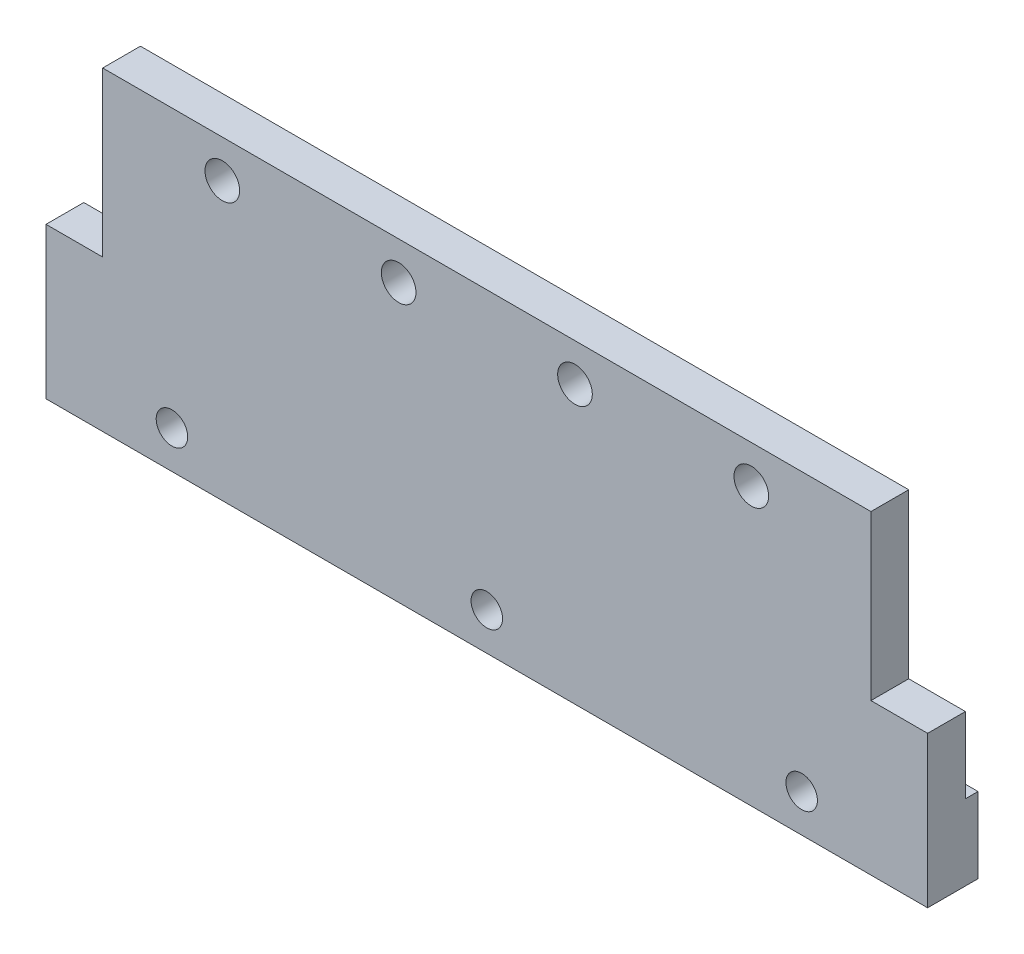
from build123d import *

# Parameters (mm, degrees)
SKETCH_1_W          = 140
SKETCH_1_H          = 50
EXTRUDE_1_DEPTH     = 6
SKETCH_6_R          = 2.75
CUT_EXTRUDE_4_DEPTH = 7
SKETCH_5_W          = 140
SKETCH_5_H          = 12
EXTRUDE_3_DEPTH     = 2
M6X1_01_AT_2_COUNT  = 2
M6X1_01_AT_2_PITCH  = 50
M6X1_01_AT_3_COUNT  = 2
M6X1_01_AT_3_PITCH  = 50
SKETCH_4_W          = 9
SKETCH_4_H          = 26
CUT_EXTRUDE_2_DEPTH = 9


with BuildPart() as part:
    # Эскиз1 → Вытянуть1 (new body)
    with BuildSketch(Plane.XY):
        Rectangle(SKETCH_1_W, SKETCH_1_H)
    extrude(amount=EXTRUDE_1_DEPTH)

    # Эскиз6 → Вытянуть4 (cut, through all)
    with BuildSketch(Plane(origin=(0, 0, 0), x_dir=(-1, 0, 0), z_dir=(0, 0, -1))):
        with Locations((42, 19)):
            Circle(SKETCH_6_R)
        with Locations((14, 19)):
            Circle(SKETCH_6_R)
        with Locations((-14, 19)):
            Circle(SKETCH_6_R)
        with Locations((-42, 19)):
            Circle(SKETCH_6_R)
    extrude(amount=-CUT_EXTRUDE_4_DEPTH, mode=Mode.SUBTRACT)

    # Эскиз5 → Вытянуть3 (add)
    with BuildSketch(Plane(origin=(0, 0, 0), x_dir=(-1, 0, 0), z_dir=(0, 0, -1))):
        with Locations((0, -19)):
            Rectangle(SKETCH_5_W, SKETCH_5_H)
    extrude(amount=EXTRUDE_3_DEPTH)

    # Эскиз2 → Отверстие обработанное метчиком M6x1.01 (revolve, cut)
    with BuildSketch(Plane(origin=(0, -19, 6), x_dir=(0, -1, 0), z_dir=(1, 0, 0))):
        Polygon((0, 0), (0, 8.000025), (3.25, 8.000025), (2.5, 7.250025), (2.5, 0), align=None)
    m6x1_01 = revolve(axis=Axis((0, -19, 12.35), (0, 0, -1)), mode=Mode.SUBTRACT)

    # Отверстие обработанное метчиком M6x1.01 at 2: Отверстие обработанное метчиком M6x1.01 ×2
    with Locations(*[(-i * M6X1_01_AT_2_PITCH, 0, 0) for i in range(1, M6X1_01_AT_2_COUNT)]):
        add(m6x1_01, mode=Mode.SUBTRACT)

    # Отверстие обработанное метчиком M6x1.01 at 3: Отверстие обработанное метчиком M6x1.01 ×2
    with Locations(*[(i * M6X1_01_AT_3_PITCH, 0, 0) for i in range(1, M6X1_01_AT_3_COUNT)]):
        add(m6x1_01, mode=Mode.SUBTRACT)

    # Эскиз4 → Вытянуть2 (cut, through all)
    with BuildSketch(Plane.XY.offset(6)):
        with Locations((-65.5, 12)):
            Rectangle(SKETCH_4_W, SKETCH_4_H)
        with Locations((65.5, 12)):
            Rectangle(SKETCH_4_W, SKETCH_4_H)
    extrude(amount=-CUT_EXTRUDE_2_DEPTH, mode=Mode.SUBTRACT)


solid = part.part
